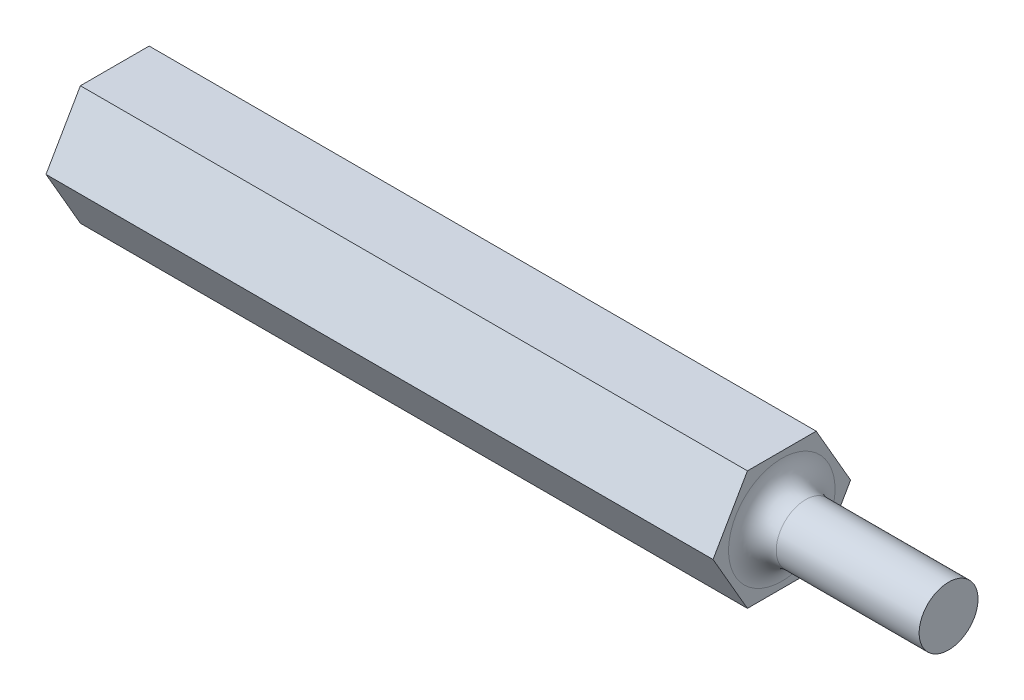
from build123d import *

# Parameters (mm, degrees)
BOSS_EXTRUDE1_DEPTH = 88.9
SKETCH2_R           = 9.399520033
SKETCH2_R_2         = 3.1369
CUT_EXTRUDE1_DEPTH  = 17.78
FILLET1_R           = 2.54


with BuildPart() as part:
    # Sketch1 → Boss-Extrude1 (new body)
    with BuildSketch(Plane(origin=(0, 0, 0), x_dir=(0, 0, -1), z_dir=(1, 0, 0))):
        Polygon((3.666174209, -6.35), (7.332348419, 0), (3.666174209, 6.35), (-3.666174209, 6.35), (-7.332348419, 0), (-3.666174209, -6.35), align=None)
    extrude(amount=BOSS_EXTRUDE1_DEPTH)

    # Sketch2 → Cut-Extrude1 (cut)
    with BuildSketch(Plane(origin=(88.9, 0, 0), x_dir=(0, 0, -1), z_dir=(1, 0, 0))):
        Circle(SKETCH2_R)
        Circle(SKETCH2_R_2, mode=Mode.SUBTRACT)
    extrude(amount=-CUT_EXTRUDE1_DEPTH, mode=Mode.SUBTRACT)

    # Fillet1
    fillet1_edges = [part.edges().sort_by_distance(p)[0] for p in [
        (71.12, 0, 3.1369),
    ]]
    fillet(fillet1_edges, radius=FILLET1_R)


solid = part.part
